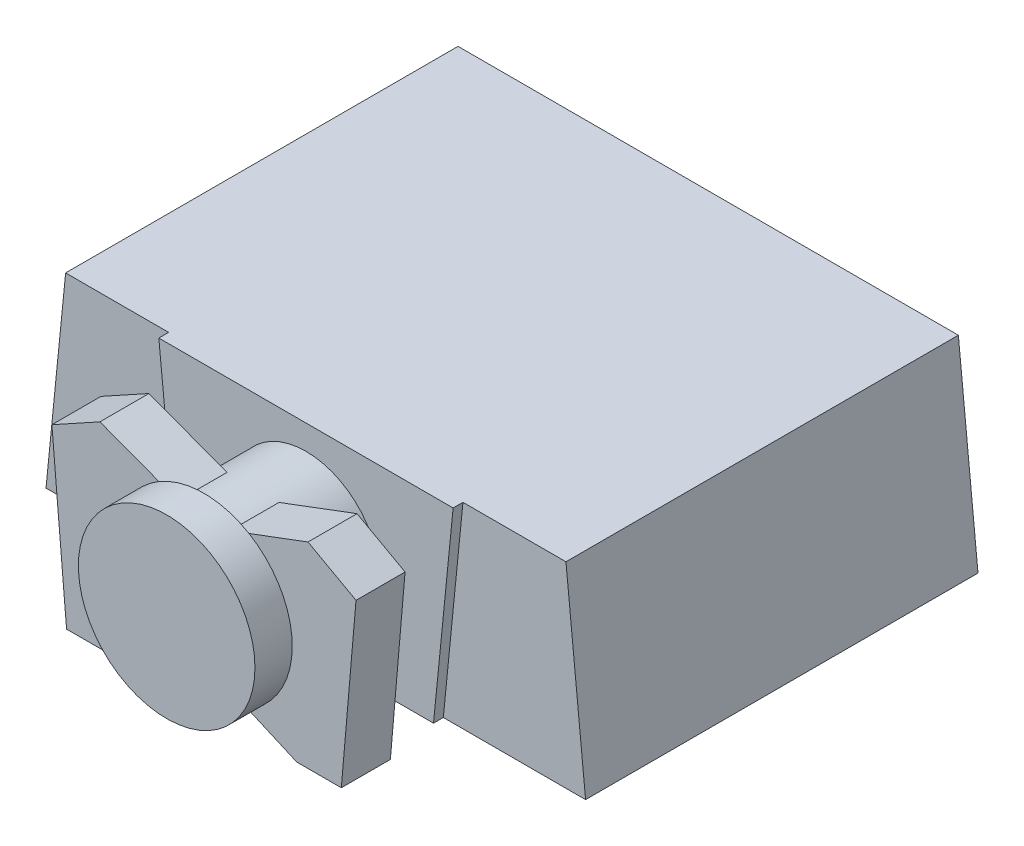
from build123d import *

# Parameters (mm, degrees)
BOSS_EXTRUDE1_DEPTH = 200
BOSS_EXTRUDE2_DEPTH = 5
SKETCH3_R           = 37.5
BOSS_EXTRUDE3_DEPTH = 27
SKETCH4_R           = 37.5
BOSS_EXTRUDE4_DEPTH = 25
SKETCH5_R           = 45
BOSS_EXTRUDE5_DEPTH = 19


with BuildPart() as part:
    # Sketch1 → Boss-Extrude1 (new body)
    with BuildSketch(Plane.XY):
        Polygon((-127.5, 50), (-137.5, -50), (137.5, -50), (127.5, 50), align=None)
    extrude(amount=-BOSS_EXTRUDE1_DEPTH)

    # Sketch2 → Boss-Extrude2 (add)
    with BuildSketch(Plane(origin=(0, 0, 0), x_dir=(-1, 0, 0), z_dir=(0, 0, -1))):
        Polygon((-75, 50), (-65, -50), (65, -50), (75, 50), align=None)
    extrude(amount=-BOSS_EXTRUDE2_DEPTH)

    # Sketch3 → Boss-Extrude3 (add)
    with BuildSketch(Plane.XY.offset(5)):
        Circle(SKETCH3_R)
    extrude(amount=BOSS_EXTRUDE3_DEPTH)

    # Sketch4 → Boss-Extrude4 (add)
    with BuildSketch(Plane.XY.offset(32)):
        with BuildLine():
            ThreePointArc((-13.263603946, -35.076014745), (-37.5, 0), (-13.263603946, 35.076014745))
            Line((-13.263603946, 35.076014745), (-53.023534566, 50))
            Line((-53.023534566, 50), (-77.5, 36.492065403))
            Line((-77.5, 36.492065403), (-70.015632516, -50))
            Line((-70.015632516, -50), (-47.291260559, -50))
            Line((-47.291260559, -50), (-13.263603946, -35.076014745))
        make_face()
        Circle(SKETCH4_R)
        with BuildLine():
            Line((53.023534566, 50), (13.263603946, 35.076014745))
            ThreePointArc((13.263603946, 35.076014745), (30.851540869, 21.317420717), (37.5, 0))
            ThreePointArc((37.5, 0), (30.851540869, -21.317420717), (13.263603946, -35.076014745))
            Line((13.263603946, -35.076014745), (47.291260559, -50))
            Line((47.291260559, -50), (70.015632516, -50))
            Line((70.015632516, -50), (77.5, 36.492065403))
            Line((77.5, 36.492065403), (53.023534566, 50))
        make_face()
    extrude(amount=BOSS_EXTRUDE4_DEPTH)

    # Sketch5 → Boss-Extrude5 (add)
    with BuildSketch(Plane.XY.offset(57)):
        Circle(SKETCH5_R)
    extrude(amount=BOSS_EXTRUDE5_DEPTH)


solid = part.part
